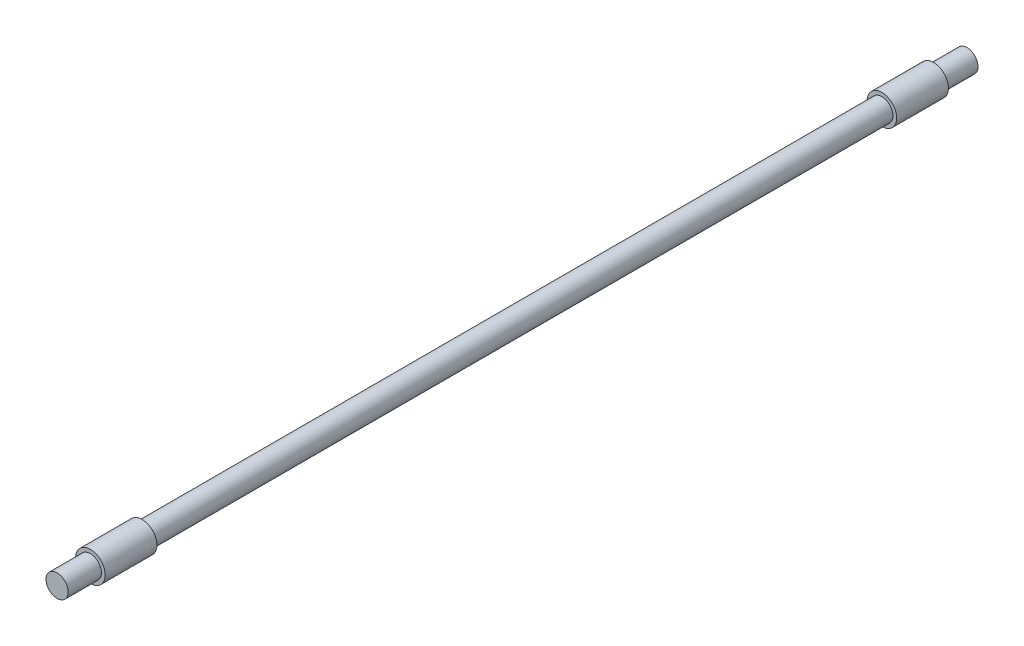
from build123d import *

# Parameters (mm, degrees)
SKETCH1_R           = 15
BOSS_EXTRUDE1_DEPTH = 1000
SKETCH2_R           = 20
BOSS_EXTRUDE2_DEPTH = 70
SKETCH3_R           = 15
BOSS_EXTRUDE3_DEPTH = 45
SKETCH4_R           = 20
BOSS_EXTRUDE4_DEPTH = 70
SKETCH5_R           = 15
BOSS_EXTRUDE5_DEPTH = 45


with BuildPart() as part:
    # Sketch1 → Boss-Extrude1 (new body)
    with BuildSketch(Plane.XY):
        Circle(SKETCH1_R)
    extrude(amount=BOSS_EXTRUDE1_DEPTH)

    # Sketch2 → Boss-Extrude2 (add)
    with BuildSketch(Plane.XY.offset(1000)):
        Circle(SKETCH2_R)
    extrude(amount=BOSS_EXTRUDE2_DEPTH)

    # Sketch3 → Boss-Extrude3 (add)
    with BuildSketch(Plane.XY.offset(1070)):
        Circle(SKETCH3_R)
    extrude(amount=BOSS_EXTRUDE3_DEPTH)

    # Sketch4 → Boss-Extrude4 (add)
    with BuildSketch(Plane(origin=(0, 0, 0), x_dir=(-1, 0, 0), z_dir=(0, 0, -1))):
        Circle(SKETCH4_R)
    extrude(amount=BOSS_EXTRUDE4_DEPTH)

    # Sketch5 → Boss-Extrude5 (add)
    with BuildSketch(Plane(origin=(0, 0, -70), x_dir=(-1, 0, 0), z_dir=(0, 0, -1))):
        Circle(SKETCH5_R)
    extrude(amount=BOSS_EXTRUDE5_DEPTH)


solid = part.part
